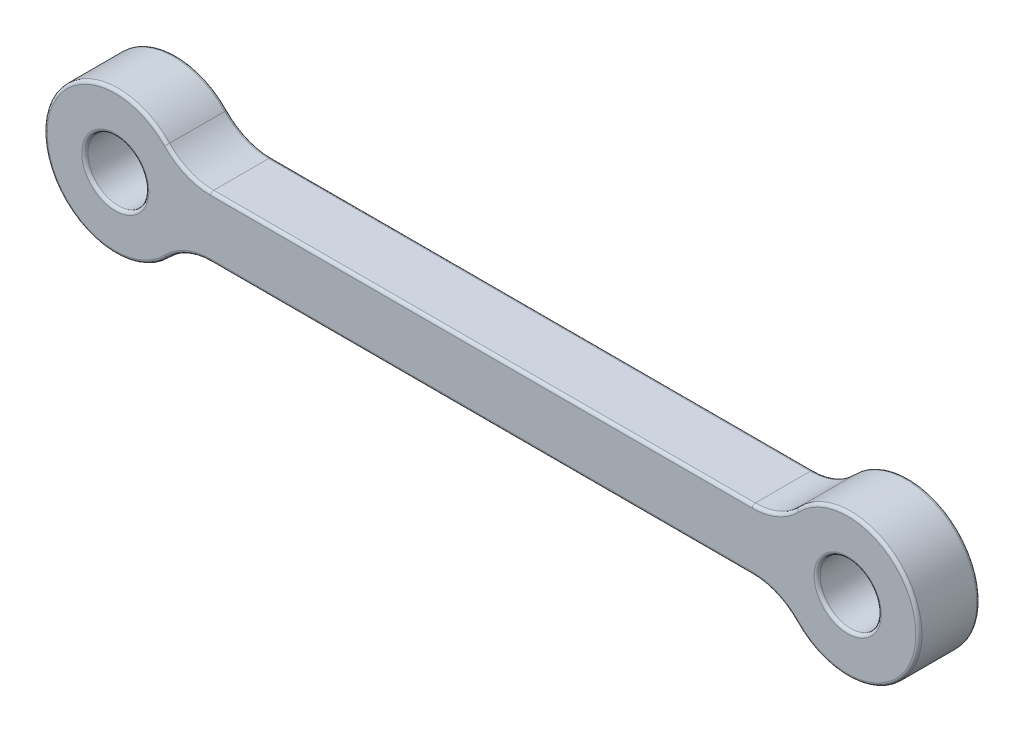
from build123d import *

# Parameters (mm, degrees)
SKETCH1_R           = 3.5
SKETCH1_R_2         = 1.5
BOSS_EXTRUDE1_DEPTH = 1.5
FILLET1_R           = 3
FILLET2_R           = 0.15


with BuildPart() as part:
    # Sketch1 → Boss-Extrude1 (new body, symmetric)
    with BuildSketch(Plane.XY):
        Circle(SKETCH1_R)
        Circle(SKETCH1_R_2, mode=Mode.SUBTRACT)
        with BuildLine():
            ThreePointArc((3.5, 0), (3.414525722, -0.768774411), (3.16227766, -1.5))
            Line((3.16227766, -1.5), (32.83772234, -1.5))
            ThreePointArc((32.83772234, -1.5), (32.5, 0), (32.83772234, 1.5))
            Line((32.83772234, 1.5), (3.16227766, 1.5))
            ThreePointArc((3.16227766, 1.5), (3.414525722, 0.768774411), (3.5, 0))
        make_face()
        with Locations((36, 0)):
            Circle(SKETCH1_R)
        with Locations((36, 0)):
            Circle(SKETCH1_R_2, mode=Mode.SUBTRACT)
    extrude(amount=BOSS_EXTRUDE1_DEPTH, both=True)

    # Fillet1
    fillet1_edges = [part.edges().sort_by_distance(p)[0] for p in [
        (32.83772234, 1.5, 0),
        (32.83772234, -1.5, 0),
        (3.16227766, -1.5, 0),
        (3.16227766, 1.5, 0),
    ]]
    fillet(fillet1_edges, radius=FILLET1_R)

    # Fillet2
    fillet2_edges = [part.edges().sort_by_distance(p)[0] for p in [
        (18, -1.5, -1.5),
        (-1.5, 0, 1.5),
        (18, -1.5, 1.5),
        (-3.5, 0, -1.5),
        (-3.5, 0, 1.5),
        (34.5, 0, 1.5),
        (39.5, 0, -1.5),
        (39.5, 0, 1.5),
        (18, 1.5, -1.5),
        (18, 1.5, 1.5),
        (3.513718949, -1.740401367, -1.5),
        (3.513718949, -1.740401367, 1.5),
        (32.486281051, -1.740401367, -1.5),
        (32.486281051, -1.740401367, 1.5),
        (32.486281051, 1.740401367, -1.5),
        (32.486281051, 1.740401367, 1.5),
        (3.513718949, 1.740401367, -1.5),
        (3.513718949, 1.740401367, 1.5),
        (34.5, 0, -1.5),
        (-1.5, 0, -1.5),
    ]]
    fillet(fillet2_edges, radius=FILLET2_R)


solid = part.part
